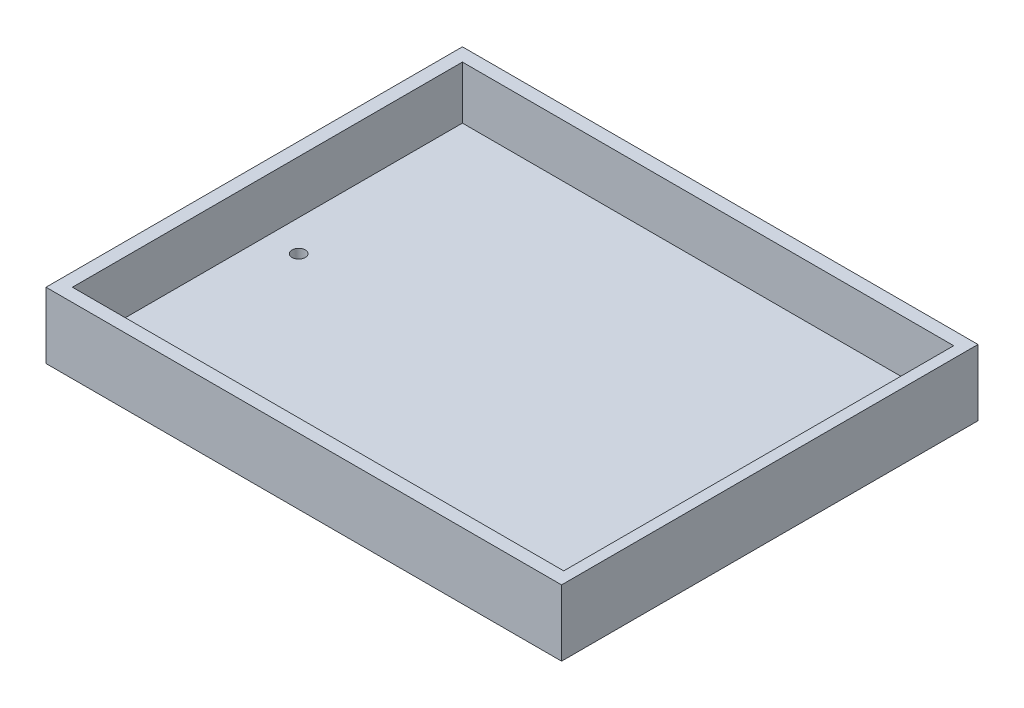
from build123d import *

# Parameters (mm, degrees)
SKETCH2_W           = 78
SKETCH2_H           = 63
BOSS_EXTRUDE1_DEPTH = 10
SKETCH3_W           = 74.327682065
SKETCH3_H           = 59
CUT_EXTRUDE1_DEPTH  = 8
CUT_EXTRUDE2_DEPTH  = 0.5
SKETCH7_R           = 1
CUT_EXTRUDE4_DEPTH  = 10


with BuildPart() as part:
    # Sketch2 → Boss-Extrude1 (new body)
    with BuildSketch(Plane(origin=(0, 0, 0), x_dir=(1, 0, 0), z_dir=(0, 1, 0))):
        with Locations((2.333333333, -2.169871795)):
            Rectangle(SKETCH2_W, SKETCH2_H)
    extrude(amount=BOSS_EXTRUDE1_DEPTH)

    # Sketch3 → Cut-Extrude1 (cut)
    with BuildSketch(Plane(origin=(0, 10, 0), x_dir=(1, 0, 0), z_dir=(0, 1, 0))):
        with Locations((2.497174366, -2.169871795)):
            Rectangle(SKETCH3_W, SKETCH3_H)
    extrude(amount=-CUT_EXTRUDE1_DEPTH, mode=Mode.SUBTRACT)

    # Sketch6 → Cut-Extrude2 (cut)
    with BuildSketch(Plane.XZ):
        with BuildLine():
            Line((32.690802989, -22.584376441), (33.092200105, -22.584376441))
            ThreePointArc((33.092200105, -22.584376441), (33.114100993, -22.618218468), (33.137410711, -22.651105984))
            Line((33.137410711, -22.651105984), (32.08626128, -24.407558571))
            Line((32.08626128, -24.407558571), (29.226689091, -24.966180766))
            Line((29.226689091, -24.966180766), (30.376407219, -24.966180766))
            Line((30.376407219, -24.966180766), (32.232099133, -24.678141196))
            Line((32.232099133, -24.678141196), (33.226175577, -23.014639973))
            Line((33.226175577, -23.014639973), (33.137410711, -24.966180766))
            Line((33.137410711, -24.966180766), (30.816462944, -26.648982972))
            Line((30.816462944, -26.648982972), (32.08626128, -26.016434732))
            Line((32.08626128, -26.016434732), (33.372391781, -25.083926351))
            Line((33.372391781, -25.083926351), (33.526915315, -22.957480273))
            Line((33.526915315, -22.957480273), (34.264738027, -25.146278223))
            Line((34.264738027, -25.146278223), (36.880788863, -26.733349716))
            Line((36.880788863, -26.733349716), (36.19146957, -26.016434732))
            Line((36.19146957, -26.016434732), (34.598609497, -24.966180766))
            Line((34.598609497, -24.966180766), (33.944592444, -23.148589195))
            Line((33.944592444, -23.148589195), (35.243832983, -24.678141196))
            Line((35.243832983, -24.678141196), (38.980139277, -25.248190523))
            Line((38.980139277, -25.248190523), (37.817752325, -24.735025947))
            Line((37.817752325, -24.735025947), (35.578982945, -24.393456258))
            Line((35.578982945, -24.393456258), (34.251613969, -22.972216889))
            Line((34.251613969, -22.972216889), (34.631588177, -22.701732047))
            ThreePointArc((34.631588177, -22.701732047), (38.008201605, -22.081175269), (34.631149946, -21.463007775))
            Line((34.631149946, -21.463007775), (34.32916984, -21.227330494))
            Line((34.32916984, -21.227330494), (35.531005717, -19.871495744))
            Line((35.531005717, -19.871495744), (37.865688927, -19.500837177))
            Line((37.865688927, -19.500837177), (39.115173896, -18.968080087))
            Line((39.115173896, -18.968080087), (35.279154236, -19.577093569))
            Line((35.279154236, -19.577093569), (33.904618441, -21.127757375))
            Line((33.904618441, -21.127757375), (34.598609497, -19.132922738))
            Line((34.598609497, -19.132922738), (36.19146957, -18.215735483))
            Line((36.19146957, -18.215735483), (36.894373516, -17.458564394))
            Line((36.894373516, -17.458564394), (34.287546919, -18.959605302))
            Line((34.287546919, -18.959605302), (33.521005252, -21.208203232))
            Line((33.521005252, -21.208203232), (33.521005252, -19.132922738))
            Line((33.521005252, -19.132922738), (32.128586258, -17.983657476))
            Line((32.128586258, -17.983657476), (30.914042032, -17.358519989))
            Line((30.914042032, -17.358519989), (33.20673173, -19.250844523))
            Line((33.20673173, -19.250844523), (33.250345457, -21.088483091))
            Line((33.250345457, -21.088483091), (32.358416357, -19.616940759))
            Line((32.358416357, -19.616940759), (30.157760841, -19.132922738))
            Line((30.157760841, -19.132922738), (29.226689091, -19.196288455))
            Line((29.226689091, -19.196288455), (32.08626128, -19.82523036))
            Line((32.08626128, -19.82523036), (33.137410711, -21.514148052))
            ThreePointArc((33.137410711, -21.514148052), (33.108673975, -21.555134418), (33.0821246, -21.597570405))
            Line((33.0821246, -21.597570405), (32.690802989, -21.597570405))
            Line((32.690802989, -21.597570405), (32.334590078, -21.674589412))
            Line((32.334590078, -21.674589412), (32.334590078, -21.93528367))
            Line((32.334590078, -21.93528367), (32.490652027, -21.862323244))
            Line((32.490652027, -21.862323244), (32.961131868, -21.935626601))
            ThreePointArc((32.961131868, -21.935626601), (32.949905472, -22.099923891), (32.967075812, -22.263706708))
            Line((32.967075812, -22.263706708), (32.490652027, -22.355724574))
            Line((32.490652027, -22.355724574), (32.320109644, -22.245819483))
            Line((32.320109644, -22.245819483), (32.334590078, -22.512171121))
            Line((32.334590078, -22.512171121), (32.690802989, -22.584376441))
        make_face()
    extrude(amount=-CUT_EXTRUDE2_DEPTH, mode=Mode.SUBTRACT)

    # Sketch7 → Cut-Extrude4 (cut)
    with BuildSketch(Plane.XZ):
        with Locations((-29.946640044, 2.169871795)):
            Circle(SKETCH7_R)
    extrude(amount=-CUT_EXTRUDE4_DEPTH, mode=Mode.SUBTRACT)


solid = part.part
